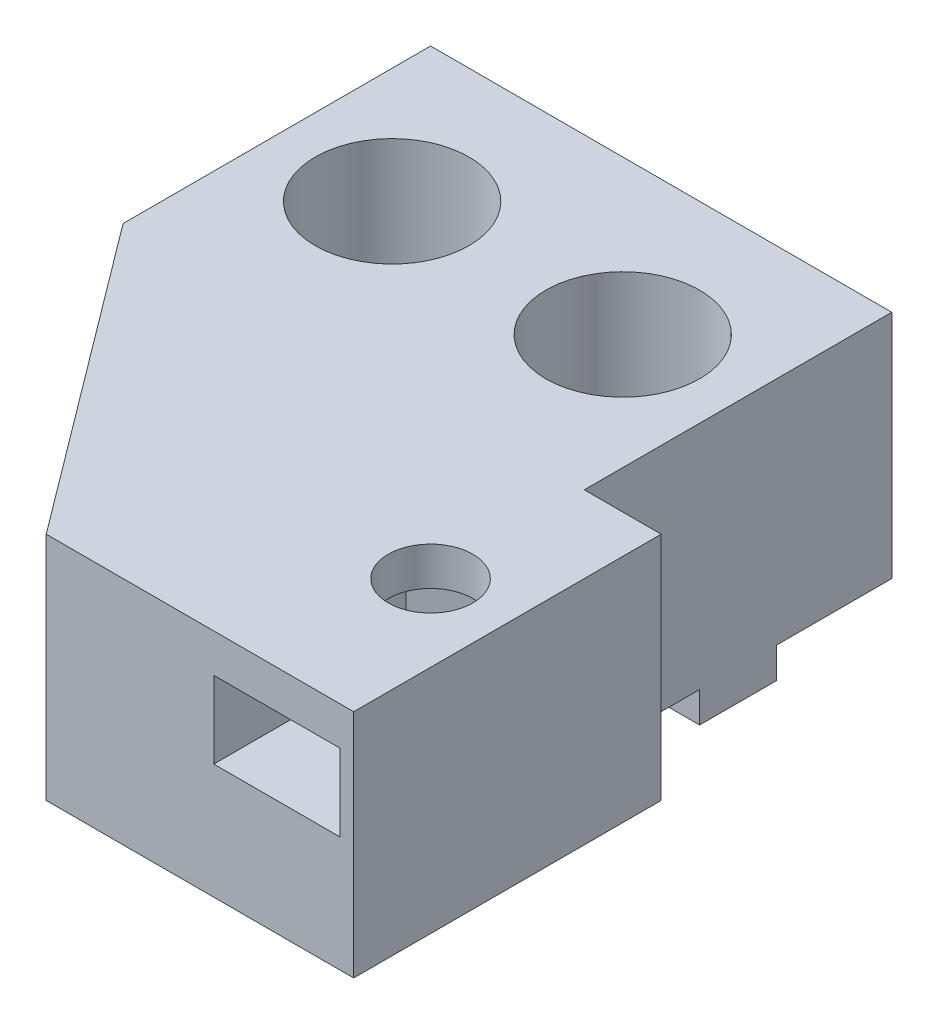
from build123d import *

# Parameters (mm, degrees)
SKETCH1_W           = 30
SKETCH1_H           = 15
BOSS_EXTRUDE1_DEPTH = 20
SKETCH2_W           = 8.2
SKETCH2_H           = 5
CUT_EXTRUDE1_DEPTH  = 21
SKETCH3_R           = 2.75
CUT_EXTRUDE2_DEPTH  = 16
BOSS_EXTRUDE2_REACH = 9.5
SKETCH5_W           = 30
SKETCH5_H           = 15
BOSS_EXTRUDE3_DEPTH = 20
SKETCH6_W           = 30
SKETCH6_H           = 5
BOSS_EXTRUDE4_DEPTH = 2
SKETCH7_R           = 2.75
CUT_EXTRUDE3_DEPTH  = 18
SKETCH8_R           = 5
CUT_EXTRUDE4_DEPTH  = 10
SKETCH10_R          = 6
CUT_EXTRUDE5_DEPTH  = 2
BOSS_EXTRUDE5_DEPTH = 15
SKETCH12_W          = 10
SKETCH12_H          = 20
CUT_EXTRUDE6_DEPTH  = 15


with BuildPart() as part:
    # Sketch1 → Boss-Extrude1 (new body)
    with BuildSketch(Plane.XY):
        with Locations((15, 7.5)):
            Rectangle(SKETCH1_W, SKETCH1_H)
    extrude(amount=BOSS_EXTRUDE1_DEPTH)

    # Sketch2 → Cut-Extrude1 (cut, through all)
    with BuildSketch(Plane.XY.offset(20)):
        with Locations((15, 10)):
            Rectangle(SKETCH2_W, SKETCH2_H)
    extrude(amount=-CUT_EXTRUDE1_DEPTH, mode=Mode.SUBTRACT)

    # Sketch3 → Cut-Extrude2 (cut, through all)
    with BuildSketch(Plane(origin=(0, 15, 0), x_dir=(1, 0, 0), z_dir=(0, 1, 0))):
        with Locations((15, -10)):
            Circle(SKETCH3_R)
    extrude(amount=-CUT_EXTRUDE2_DEPTH, mode=Mode.SUBTRACT)

    # Sketch4 → Boss-Extrude2 (add, up to next)
    with BuildSketch(Plane(origin=(0, 7.5, 0), x_dir=(1, 0, 0), z_dir=(0, 1, 0)), mode=Mode.PRIVATE) as boss_extrude2_sk1:
        Polygon((19.1, -7.5), (15.1, -5.133920143), (10.9, -7.5), (10.9, 0), (19.1, 0), align=None)
    boss_extrude2_tool1 = extrude(boss_extrude2_sk1.sketch, amount=BOSS_EXTRUDE2_REACH, mode=Mode.PRIVATE) - part.part
    add(boss_extrude2_tool1.solids().sort_by_distance((14.993757, 7.5, 3.195407))[0])

    # Sketch5 → Boss-Extrude3 (add)
    with BuildSketch(Plane(origin=(0, 0, 0), x_dir=(-1, 0, 0), z_dir=(0, 0, -1))):
        with Locations((0, 7.5)):
            Rectangle(SKETCH5_W, SKETCH5_H)
    extrude(amount=BOSS_EXTRUDE3_DEPTH)

    # Sketch6 → Boss-Extrude4 (add)
    with BuildSketch(Plane.XZ):
        with Locations((0, -10)):
            Rectangle(SKETCH6_W, SKETCH6_H)
    extrude(amount=BOSS_EXTRUDE4_DEPTH)

    # Sketch7 → Cut-Extrude3 (cut, through all)
    with BuildSketch(Plane(origin=(0, 15, 0), x_dir=(1, 0, 0), z_dir=(0, 1, 0))):
        with Locations((7.5, 10)):
            Circle(SKETCH7_R)
        with Locations((-7.5, 10)):
            Circle(SKETCH7_R)
    extrude(amount=-CUT_EXTRUDE3_DEPTH, mode=Mode.SUBTRACT)

    # Sketch8 → Cut-Extrude4 (cut)
    with BuildSketch(Plane(origin=(0, 15, 0), x_dir=(1, 0, 0), z_dir=(0, 1, 0))):
        with Locations((7.5, 10)):
            Circle(SKETCH8_R)
        with Locations((-7.5, 10)):
            Circle(SKETCH8_R)
    extrude(amount=-CUT_EXTRUDE4_DEPTH, mode=Mode.SUBTRACT)

    # Sketch10 → Cut-Extrude5 (cut)
    with BuildSketch(Plane.XZ.offset(2)):
        with Locations((-7.5, -10)):
            Circle(SKETCH10_R)
        with Locations((7.5, -10)):
            Circle(SKETCH10_R)
    extrude(amount=-CUT_EXTRUDE5_DEPTH, mode=Mode.SUBTRACT)

    # Sketch11 → Boss-Extrude5 (add)
    with BuildSketch(Plane(origin=(0, 15, 0), x_dir=(1, 0, 0), z_dir=(0, 1, 0))):
        Polygon((-15, 0), (0, -20), (0, 0), align=None)
    extrude(amount=-BOSS_EXTRUDE5_DEPTH)

    # Sketch12 → Cut-Extrude6 (cut)
    with BuildSketch(Plane(origin=(0, 15, 0), x_dir=(1, 0, 0), z_dir=(0, 1, 0))):
        with Locations((25, -10)):
            Rectangle(SKETCH12_W, SKETCH12_H)
    extrude(amount=-CUT_EXTRUDE6_DEPTH, mode=Mode.SUBTRACT)


solid = part.part
